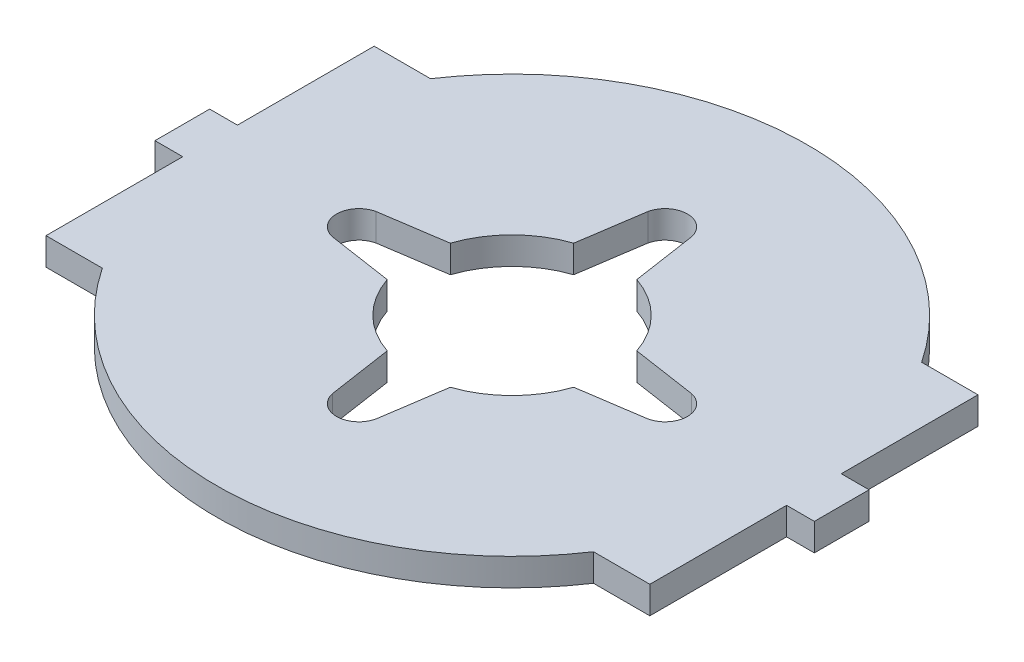
from build123d import *

# Parameters (mm, degrees)
SKETCH1_W                                = 70.104
SKETCH1_H                                = 38.1
RECTANGULAR_BASE_DEPTH                   = 3.175
SKETCH2_R                                = 34.29
CIRCULAR_BASE_ADD_ON_DEPTH               = 3.175
HOLE_FOR_SERVO_ARM_DEPTH                 = 4.175
TAB_DEPTH                                = 3.175
CIRCULAR_PATTERN_OF_SERVO_ARM_HOLE_COUNT = 4
SKETCH6_R                                = 11.43
CUT_EXTRUDE2_DEPTH                       = 4.175


with BuildPart() as part:
    # Sketch1 → rectangular base (new body)
    with BuildSketch(Plane(origin=(0, 0, 0), x_dir=(1, 0, 0), z_dir=(0, 1, 0))):
        Rectangle(SKETCH1_W, SKETCH1_H)
    extrude(amount=RECTANGULAR_BASE_DEPTH)

    # Sketch2 → circular base add on (add)
    with BuildSketch(Plane(origin=(0, 3.175, 0), x_dir=(1, 0, 0), z_dir=(0, 1, 0))):
        Circle(SKETCH2_R)
    extrude(amount=-CIRCULAR_BASE_ADD_ON_DEPTH)

    # Sketch3 → hole for servo arm (cut, through all)
    with BuildSketch(Plane(origin=(0, 3.175, 0), x_dir=(1, 0, 0), z_dir=(0, 1, 0))):
        with BuildLine():
            Line((-2.54, 18.306077), (-4.445, 5.588))
            Line((-4.445, 5.588), (-5.881840979, 4.151159021))
            Line((-5.881840979, 4.151159021), (0, 0))
            Line((0, 0), (5.881840979, 4.151159021))
            Line((5.881840979, 4.151159021), (4.445, 5.588))
            Line((4.445, 5.588), (2.54, 18.306077))
            ThreePointArc((2.54, 18.306077), (0, 20.366046175), (-2.54, 18.306077))
        make_face()
    hole_for_servo_arm = extrude(amount=-HOLE_FOR_SERVO_ARM_DEPTH, mode=Mode.SUBTRACT)

    # Sketch4 → tab (add)
    with BuildSketch(Plane(origin=(0, 3.175, 0), x_dir=(1, 0, 0), z_dir=(0, 1, 0))):
        Polygon((-35.052, 0), (-35.052, 3.175), (-38.2778, 3.175), (-38.2778, -3.175), (-35.052, -3.175), align=None)
    tab = extrude(amount=-TAB_DEPTH)

    # Mirror1: tab across plane
    add(tab.mirror(Plane(origin=(0, 0, 0), x_dir=(0, 0, 1), z_dir=(1, 0, 0))))

    # Circular pattern of servo arm hole: hole for servo arm ×4 about axis
    circular_pattern_of_servo_arm_hole_axis = Axis((0, 0, 0), (0, 1, 0))
    for i in range(1, CIRCULAR_PATTERN_OF_SERVO_ARM_HOLE_COUNT):
        add(hole_for_servo_arm.rotate(circular_pattern_of_servo_arm_hole_axis, i * 360 / CIRCULAR_PATTERN_OF_SERVO_ARM_HOLE_COUNT), mode=Mode.SUBTRACT)

    # Sketch6 → Cut-Extrude2 (cut, through all)
    with BuildSketch(Plane(origin=(0, 3.175, 0), x_dir=(1, 0, 0), z_dir=(0, 1, 0))):
        Circle(SKETCH6_R)
    extrude(amount=-CUT_EXTRUDE2_DEPTH, mode=Mode.SUBTRACT)


solid = part.part
